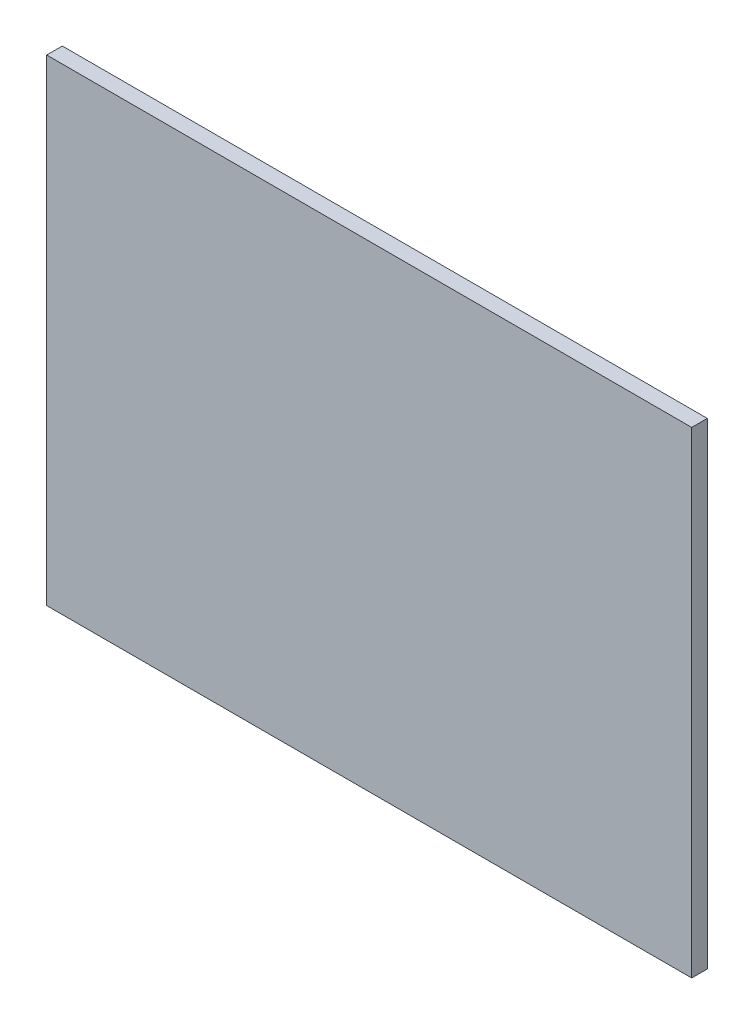
from build123d import *

# Parameters (mm, degrees)
SKETCH1_W           = 744
SKETCH1_H           = 550
BOSS_EXTRUDE1_DEPTH = 18


with BuildPart() as part:
    # Sketch1 → Boss-Extrude1 (new body)
    with BuildSketch(Plane.XY):
        Rectangle(SKETCH1_W, SKETCH1_H)
    extrude(amount=BOSS_EXTRUDE1_DEPTH)


solid = part.part
